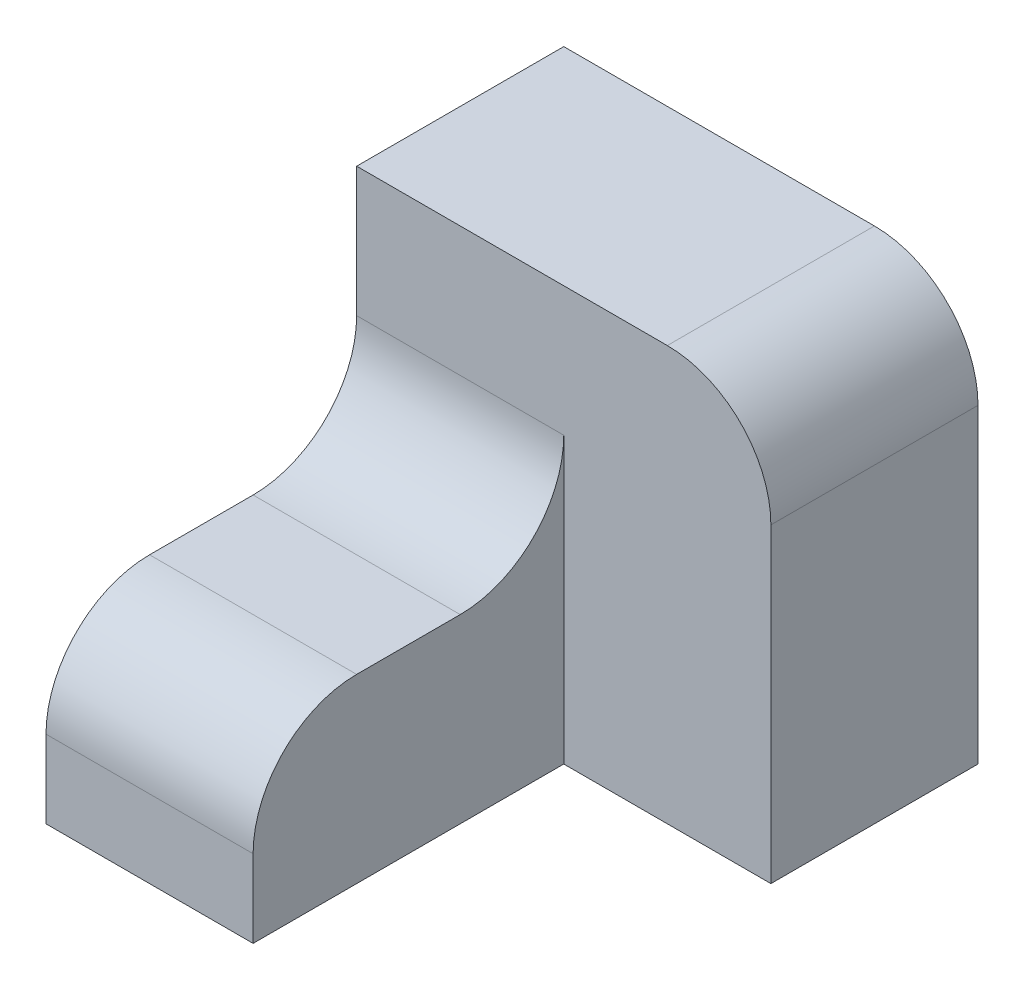
from build123d import *

# Parameters (mm, degrees)
SKETCH1_W           = 20
SKETCH1_H           = 17.5
BOSS_EXTRUDE1_DEPTH = 30
SKETCH2_W           = 40
SKETCH2_H           = 40
BOSS_EXTRUDE2_DEPTH = 20
FILLET1_R           = 10


with BuildPart() as part:
    # Sketch1 → Boss-Extrude1 (new body)
    with BuildSketch(Plane.XY):
        with Locations((-20, -8.75)):
            Rectangle(SKETCH1_W, SKETCH1_H)
    extrude(amount=BOSS_EXTRUDE1_DEPTH)

    # Sketch2 → Boss-Extrude2 (add)
    with BuildSketch(Plane.XY):
        with Locations((-10, 2.5)):
            Rectangle(SKETCH2_W, SKETCH2_H)
    extrude(amount=-BOSS_EXTRUDE2_DEPTH)

    # Fillet1
    fillet1_edges = [part.edges().sort_by_distance(p)[0] for p in [
        (10, 22.5, -10),
        (-20, 0, 30),
        (-20, 0, 0),
    ]]
    fillet(fillet1_edges, radius=FILLET1_R)


solid = part.part
